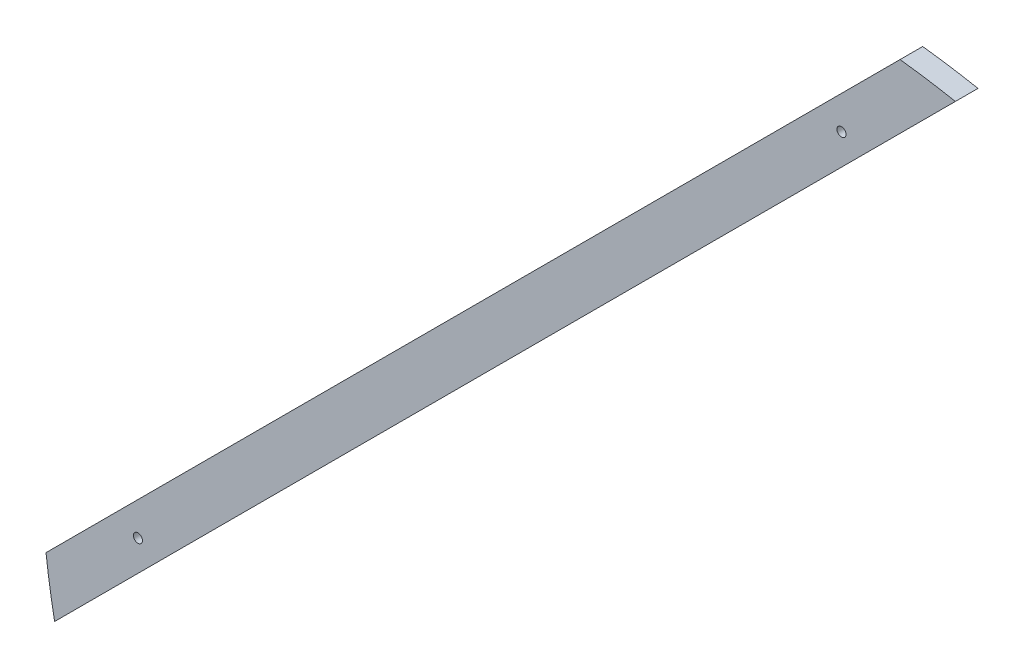
from build123d import *

# Parameters (mm, degrees)
BOSS_EXTRU_1_DEPTH      = 5
ESQUISSE5_R             = 1
ENL_V_MAT_EXTRU_1_DEPTH = 6


with BuildPart() as part:
    # Esquisse4 → Boss.-Extru.1 (new body)
    with BuildSketch(Plane.XY):
        with BuildLine():
            Line((20.029174718, 168.815971283), (15.07942725, 163.866223814))
            Line((15.07942725, 163.866223814), (-163.866223814, -15.07942725))
            Line((-163.866223814, -15.07942725), (-168.815971283, -20.029174718))
            ThreePointArc((-168.815971283, -20.029174718), (-167.974440879, -26.164617549), (-166.909999486, -32.265338546))
            Line((-166.909999486, -32.265338546), (-156.795156002, -22.150495062))
            Line((-156.795156002, -22.150495062), (22.150495062, 156.795156002))
            Line((22.150495062, 156.795156002), (32.265338546, 166.909999486))
            ThreePointArc((32.265338546, 166.909999486), (26.164617549, 167.974440879), (20.029174718, 168.815971283))
        make_face()
    extrude(amount=BOSS_EXTRU_1_DEPTH)

    # Esquisse5 → Enlèv. mat.-Extru.1 (cut, through all)
    with BuildSketch(Plane(origin=(0, 0, 0), x_dir=(-1, 0, 0), z_dir=(0, 0, -1))):
        with Locations((148.492424049, -7.071067812)):
            Circle(ESQUISSE5_R)
        with Locations((-7.071067812, 148.492424049)):
            Circle(ESQUISSE5_R)
    extrude(amount=-ENL_V_MAT_EXTRU_1_DEPTH, mode=Mode.SUBTRACT)


solid = part.part
